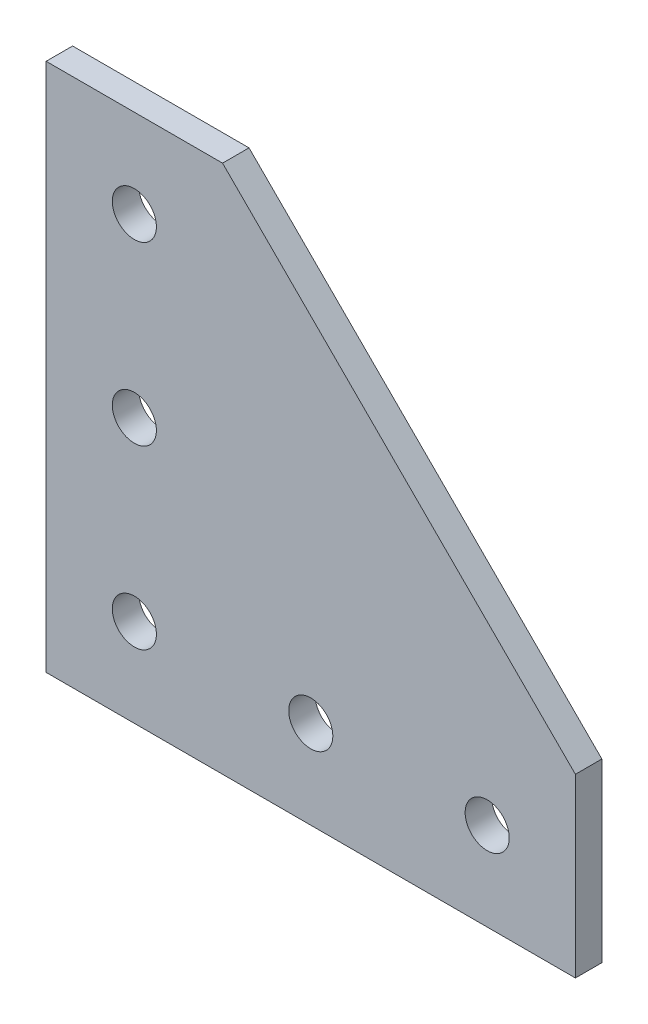
from build123d import *

# Parameters (mm, degrees)
BOSS_EXTRUDE1_DEPTH = 3
SKETCH2_R           = 2.5
CUT_EXTRUDE1_DEPTH  = 3


with BuildPart() as part:
    # Sketch1 → Boss-Extrude1 (new body)
    with BuildSketch(Plane.XY):
        Polygon((0, 60), (20, 60), (60, 20), (60, 0), (0, 0), align=None)
    extrude(amount=-BOSS_EXTRUDE1_DEPTH)

    # Sketch2 → Cut-Extrude1 (cut)
    with BuildSketch(Plane.XY):
        with Locations((10, 10)):
            Circle(SKETCH2_R)
        with Locations((30, 10)):
            Circle(SKETCH2_R)
        with Locations((50, 10)):
            Circle(SKETCH2_R)
        with Locations((10, 30)):
            Circle(SKETCH2_R)
        with Locations((10, 50)):
            Circle(SKETCH2_R)
    extrude(amount=-CUT_EXTRUDE1_DEPTH, mode=Mode.SUBTRACT)


solid = part.part
